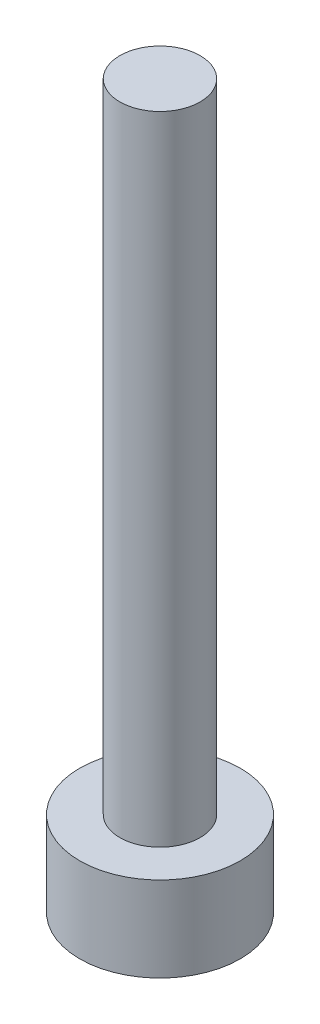
from build123d import *

# Parameters (mm, degrees)
SKETCH1_W   = 2.999994
SKETCH1_H   = 47.625
SKETCH1_W_2 = 6
SKETCH1_H_2 = 6.35


with BuildPart() as part:
    # Sketch1 → Revolve1 (revolve)
    with BuildSketch(Plane.XY):
        with Locations((-1.499997, 30.1625)):
            Rectangle(SKETCH1_W, SKETCH1_H)
        with Locations((-3, 3.175)):
            Rectangle(SKETCH1_W_2, SKETCH1_H_2)
    revolve(axis=Axis((0, 6.35, 0), (0, 1, 0)))


solid = part.part
